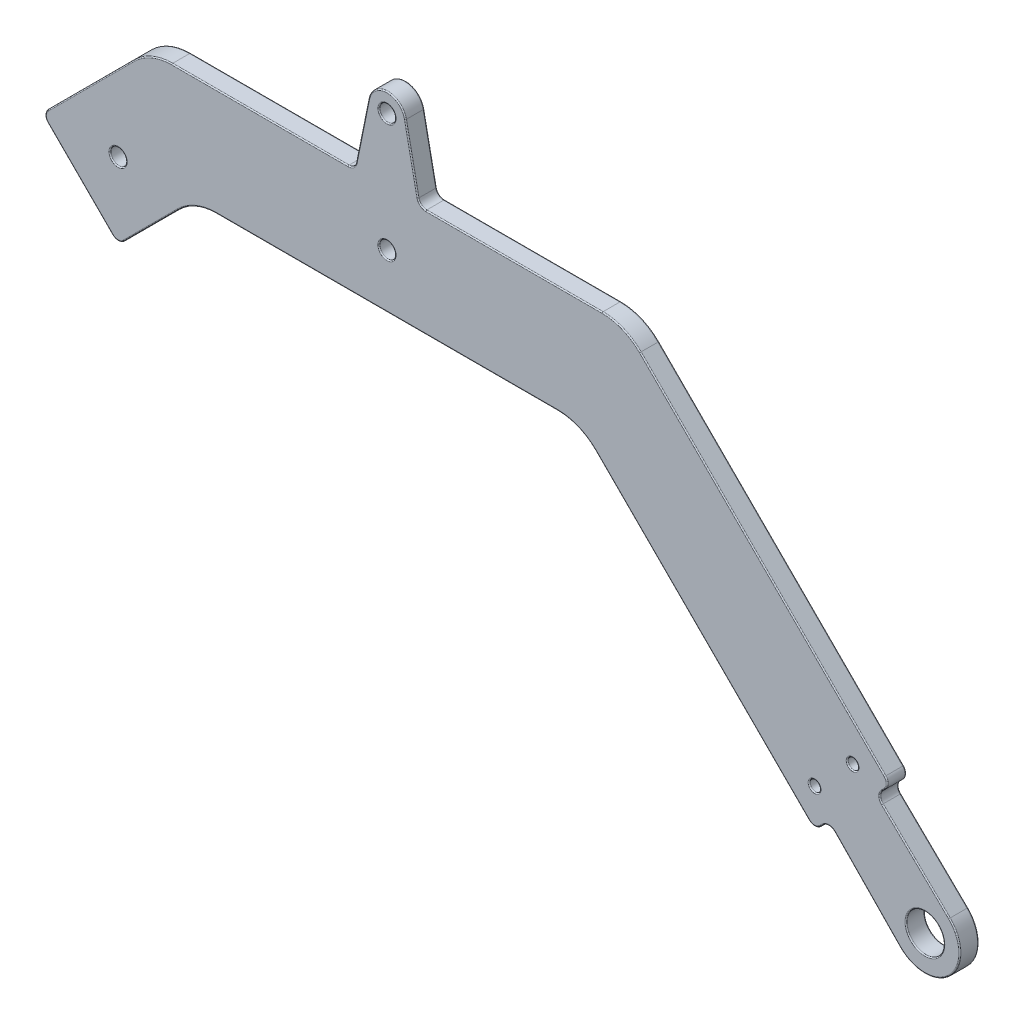
from build123d import *

# Parameters (mm, degrees)
SKETCH7_R           = 1
SKETCH7_R_2         = 3.5
SKETCH7_R_3         = 1.5
BOSS_EXTRUDE1_DEPTH = 3.5
FILLET1_R           = 10
FILLET2_R           = 1.5
FILLET3_R           = 0.2


with BuildPart() as part:
    # Sketch7 → Boss-Extrude1 (new body)
    with BuildSketch(Plane.XY):
        with BuildLine():
            Line((90.980851591, 17.850909276), (104.533955357, 4.657601188))
            ThreePointArc((104.533955357, 4.657601188), (104.596194078, -4.596194078), (95.342398812, -4.533955357))
            Line((95.342398812, -4.533955357), (82.149090724, 9.019148409))
            Line((82.149090724, 9.019148409), (79.493903346, 6.363961031))
            Line((79.493903346, 6.363961031), (35.857864376, 50))
            Line((35.857864376, 50), (-35.857864376, 50))
            Line((-35.857864376, 50), (-50, 35.857864376))
            Line((-50, 35.857864376), (-64.142135624, 50))
            Line((-64.142135624, 50), (-44.142135624, 70))
            Line((-44.142135624, 70), (-6, 70))
            Line((-6, 70), (-3.430427898, 82.694380615))
            ThreePointArc((-3.430427898, 82.694380615), (0, 85.5), (3.430427898, 82.694380615))
            Line((3.430427898, 82.694380615), (6, 70))
            Line((6, 70), (44.142135624, 70))
            Line((44.142135624, 70), (93.636038969, 20.506096654))
            Line((93.636038969, 20.506096654), (90.980851591, 17.850909276))
        make_face()
        with Locations((86.564971157, 20.506096654)):
            Circle(SKETCH7_R, mode=Mode.SUBTRACT)
        with Locations((100, 0)):
            Circle(SKETCH7_R_2, mode=Mode.SUBTRACT)
        with Locations((0, 82)):
            Circle(SKETCH7_R_3, mode=Mode.SUBTRACT)
        with Locations((0, 60)):
            Circle(SKETCH7_R_3, mode=Mode.SUBTRACT)
        with Locations((79.493903346, 13.435028843)):
            Circle(SKETCH7_R, mode=Mode.SUBTRACT)
        with Locations((-50, 50)):
            Circle(SKETCH7_R_3, mode=Mode.SUBTRACT)
    extrude(amount=BOSS_EXTRUDE1_DEPTH)

    # Fillet1
    fillet1_edges = [part.edges().sort_by_distance(p)[0] for p in [
        (35.857864376, 50, 1.75),
        (-35.857864376, 50, 1.75),
        (-44.142135624, 70, 1.75),
        (44.142135624, 70, 1.75),
    ]]
    fillet(fillet1_edges, radius=FILLET1_R)

    # Fillet2
    fillet2_edges = [part.edges().sort_by_distance(p)[0] for p in [
        (90.980851591, 17.850909276, 1.75),
        (82.149090724, 9.019148409, 1.75),
        (79.493903346, 6.363961031, 1.75),
        (-50, 35.857864376, 1.75),
        (-64.142135624, 50, 1.75),
        (-6, 70, 1.75),
        (6, 70, 1.75),
        (93.636038969, 20.506096654, 1.75),
    ]]
    fillet(fillet2_edges, radius=FILLET2_R)

    # Fillet3
    fillet3_edges = [part.edges().sort_by_distance(p)[0] for p in [
        (-43.863068196, 41.99479618, 3.5),
        (-23.613397104, 70, 0),
        (4.593519361, 76.948394462, 0),
        (69.823223305, 44.318912319, 0),
        (92.315627321, 19.185685006, 0),
        (89.275978249, 1.697903009, 0),
        (80.814314994, 7.684372679, 0),
        (-57.071067812, 42.928932188, 0),
        (79.493903346, 6.985281374, 0),
        (93.014718626, 20.506096654, 0),
        (-63.52081528, 50, 0),
        (-50, 36.47918472, 0),
        (-57.071067812, 42.928932188, 3.5),
        (-23.613397104, 70, 3.5),
        (80.814314994, 7.684372679, 3.5),
        (89.275978249, 1.697903009, 3.5),
        (92.315627321, 19.185685006, 3.5),
        (69.823223305, 44.318912319, 3.5),
        (4.593519361, 76.948394462, 3.5),
        (79.493903346, 6.985281374, 3.5),
        (93.014718626, 20.506096654, 3.5),
        (-63.52081528, 50, 3.5),
        (-50, 36.47918472, 3.5),
        (-6.27715942, 70.338882534, 0),
        (-6.27715942, 70.338882534, 3.5),
        (6.27715942, 70.338882534, 0),
        (6.27715942, 70.338882534, 3.5),
        (91.616569941, 17.855184959, 0),
        (91.616569941, 17.855184959, 3.5),
        (82.144815041, 8.383430059, 0),
        (82.144815041, 8.383430059, 3.5),
        (98.302096991, 10.724021751, 0),
        (104.596194078, -4.596194078, 0),
        (-4.593519361, 76.948394462, 0),
        (0, 85.5, 0),
        (0, 85.5, 3.5),
        (-4.593519361, 76.948394462, 3.5),
        (85.564971157, 20.506096654, 0),
        (85.564971157, 20.506096654, 3.5),
        (96.5, 0, 0),
        (96.5, 0, 3.5),
        (-1.5, 82, 0),
        (-1.5, 82, 3.5),
        (-1.5, 60, 0),
        (-1.5, 60, 3.5),
        (78.493903346, 13.435028843, 0),
        (78.493903346, 13.435028843, 3.5),
        (-51.5, 50, 0),
        (-51.5, 50, 3.5),
        (104.596194078, -4.596194078, 3.5),
        (98.302096991, 10.724021751, 3.5),
        (0, 50, 0),
        (0, 50, 3.5),
        (58.610019869, 27.247844507, 0),
        (58.610019869, 27.247844507, 3.5),
        (-55.076271632, 59.065863992, 0),
        (-55.076271632, 59.065863992, 3.5),
        (23.613397104, 70, 0),
        (43.826834324, 69.238795325, 0),
        (-43.826834324, 69.238795325, 0),
        (23.613397104, 70, 3.5),
        (43.826834324, 69.238795325, 3.5),
        (-43.826834324, 69.238795325, 3.5),
        (-35.542563076, 49.238795325, 0),
        (-35.542563076, 49.238795325, 3.5),
        (35.542563076, 49.238795325, 0),
        (35.542563076, 49.238795325, 3.5),
        (-43.863068196, 41.99479618, 0),
    ]]
    fillet(fillet3_edges, radius=FILLET3_R)


solid = part.part
